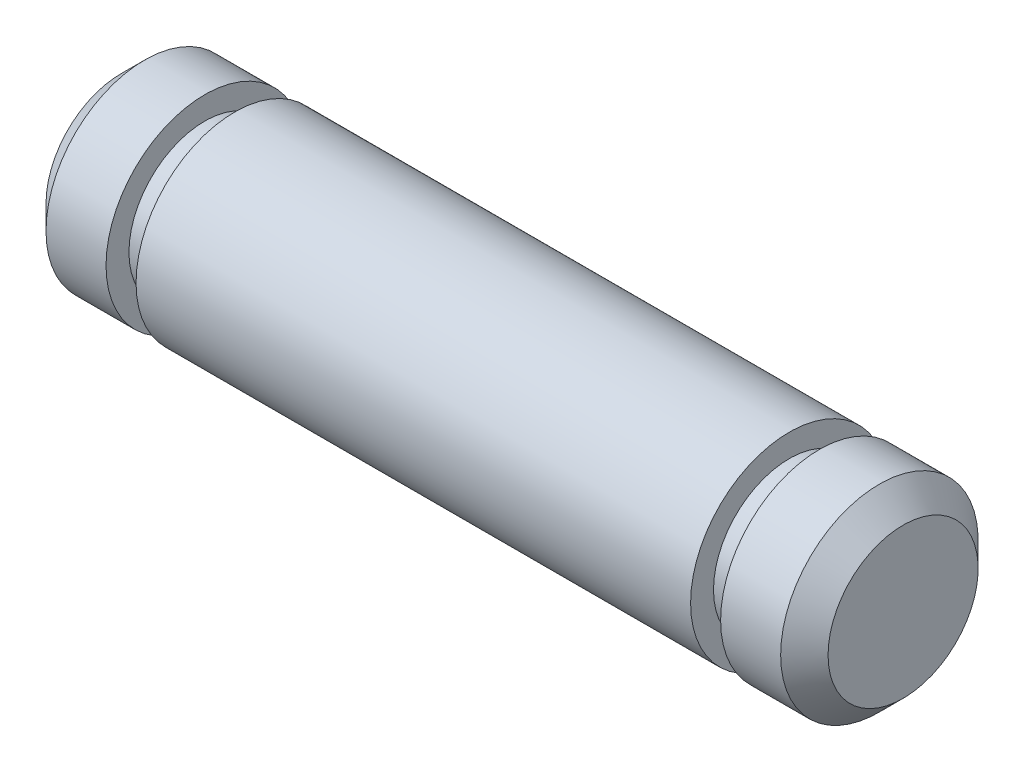
from build123d import *


with BuildPart() as part:
    # Sketch1 → Revolve1 (revolve)
    with BuildSketch(Plane.XY):
        Polygon((-6.2865, 0), (-6.2865, 1.2065), (-5.9055, 1.5875), (-4.9403, 1.5875), (-4.9403, 1.2192), (-4.4577, 1.2192), (-4.4577, 1.5875), (4.4577, 1.5875), (4.4577, 1.2192), (4.9403, 1.2192), (4.9403, 1.5875), (5.9055, 1.5875), (6.2865, 1.2065), (6.2865, 0), align=None)
    revolve(axis=Axis((6.2865, 0, 0), (-1, 0, 0)))


solid = part.part
